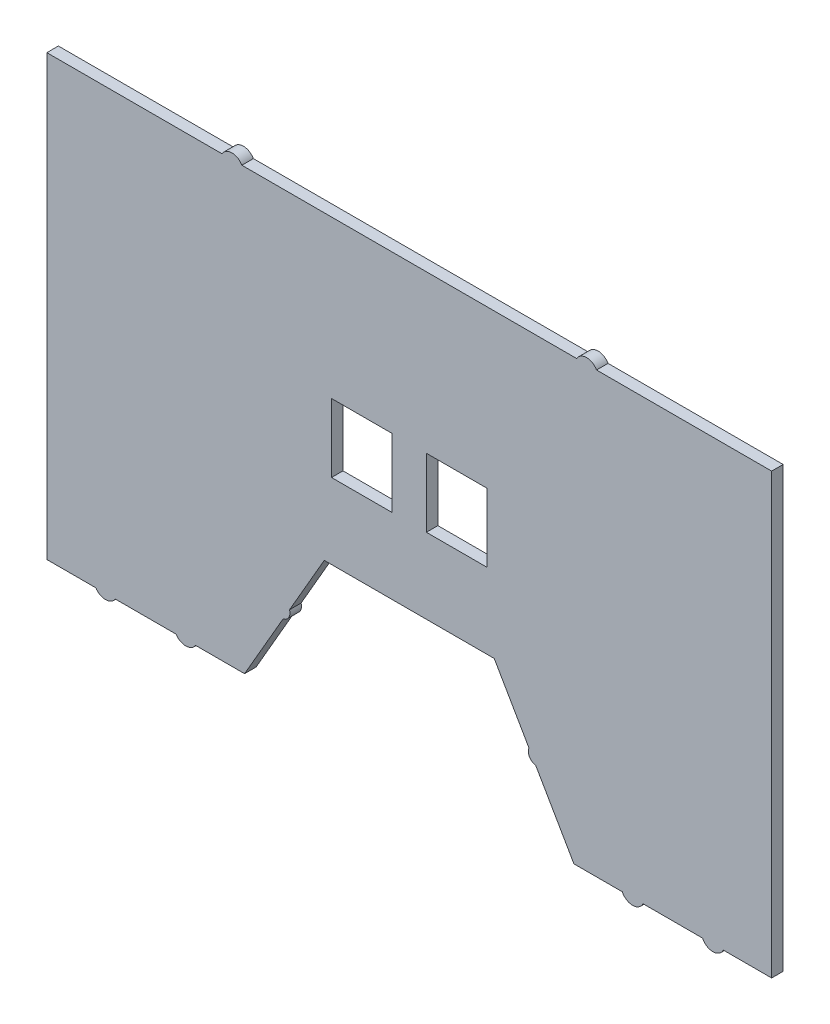
from build123d import *

# Parameters (mm, degrees)
SKETCH1_W           = 26.358753283
SKETCH1_H           = 29.759882739
BOSS_EXTRUDE1_DEPTH = 5


with BuildPart() as part:
    # Sketch1 → Boss-Extrude1 (new body)
    with BuildSketch(Plane.XY):
        with BuildLine():
            Line((-133.705700246, -95.388044307), (-107.275003874, -95.388044307))
            ThreePointArc((-107.275003874, -95.388044307), (-103.044823488, -97.722416069), (-98.814643102, -95.388044307))
            Line((-98.814643102, -95.388044307), (-77.510422411, -95.388044307))
            Line((-77.510422411, -95.388044307), (-60.765070658, -66.384244279))
            ThreePointArc((-60.765070658, -66.384244279), (-58.284996417, -64.588629688), (-57.969985686, -61.543015096))
            Line((-57.969985686, -61.543015096), (-42.86940626, -35.388044307))
            Line((-42.86940626, -35.388044307), (31.031428196, -35.388044307))
            Line((31.031428196, -35.388044307), (46.120827825, -61.523651119))
            ThreePointArc((46.120827825, -61.523651119), (46.354900962, -64.791664092), (49.068046647, -66.628383861))
            Line((49.068046647, -66.628383861), (65.672444348, -95.388044307))
            Line((65.672444348, -95.388044307), (86.685893367, -95.388044307))
            ThreePointArc((86.685893367, -95.388044307), (91.206010968, -98.250630713), (95.726128569, -95.388044307))
            Line((95.726128569, -95.388044307), (121.578619423, -95.388044307))
            ThreePointArc((121.578619423, -95.388044307), (126.098737025, -98.250630713), (130.618854626, -95.388044307))
            Line((130.618854626, -95.388044307), (151.632303645, -95.388044307))
            Line((151.632303645, -95.388044307), (151.632303645, 95.46540018))
            Line((151.632303645, 95.46540018), (75.512150198, 95.46540018))
            ThreePointArc((75.512150198, 95.46540018), (71.182023179, 97.96540018), (66.85189616, 95.46540018))
            Line((66.85189616, 95.46540018), (-78.689780736, 95.46540018))
            ThreePointArc((-78.689780736, 95.46540018), (-83.019907754, 97.96540018), (-87.350034773, 95.46540018))
            Line((-87.350034773, 95.46540018), (-163.470281709, 95.46540018))
            Line((-163.470281709, 95.46540018), (-163.470281709, -95.388044307))
            Line((-163.470281709, -95.388044307), (-142.166061018, -95.388044307))
            ThreePointArc((-142.166061018, -95.388044307), (-137.935880632, -97.722416069), (-133.705700246, -95.388044307))
        make_face()
        with Locations((-26.546016438, 12.255373732)):
            Rectangle(SKETCH1_W, SKETCH1_H, mode=Mode.SUBTRACT)
        with Locations((14.708131863, 12.255373732)):
            Rectangle(SKETCH1_W, SKETCH1_H, mode=Mode.SUBTRACT)
    extrude(amount=BOSS_EXTRUDE1_DEPTH)


solid = part.part
